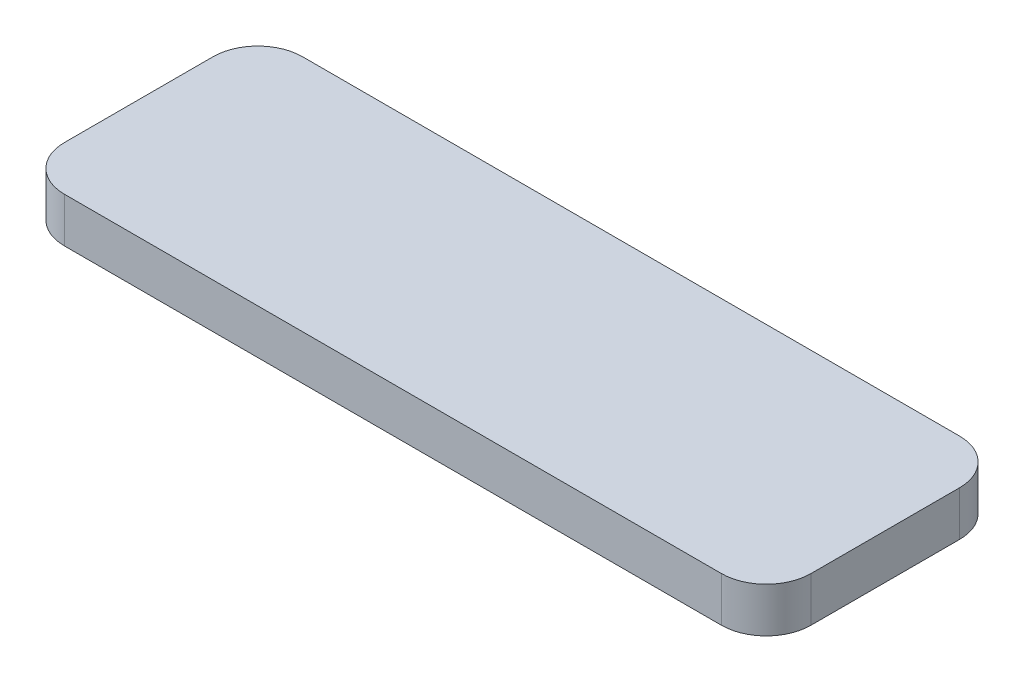
from build123d import *

# Parameters (mm, degrees)
SKETCH1_W           = 50
SKETCH1_H           = 15.95
BOSS_EXTRUDE1_DEPTH = 3
FILLET1_R           = 3


with BuildPart() as part:
    # Sketch1 → Boss-Extrude1 (new body)
    with BuildSketch(Plane(origin=(0, 0, 0), x_dir=(1, 0, 0), z_dir=(0, 1, 0))):
        with Locations((25, 7.975)):
            Rectangle(SKETCH1_W, SKETCH1_H)
    extrude(amount=BOSS_EXTRUDE1_DEPTH)

    # Fillet1
    fillet1_edges = [part.edges().sort_by_distance(p)[0] for p in [
        (0, 1.5, -15.95),
        (50, 1.5, -15.95),
        (50, 1.5, 0),
        (0, 1.5, 0),
    ]]
    fillet(fillet1_edges, radius=FILLET1_R)


solid = part.part
